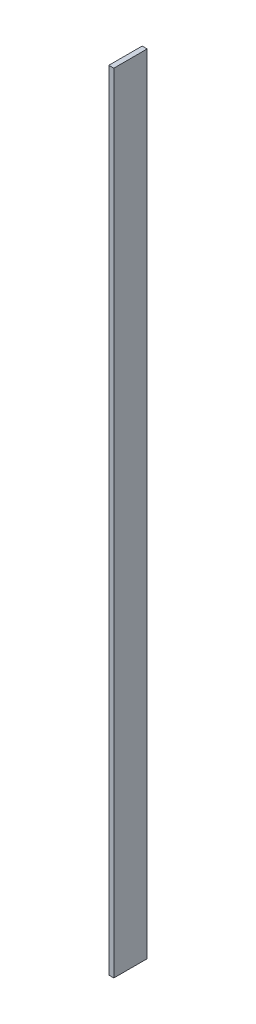
from build123d import *

# Parameters (mm, degrees)
SKETCH1_W           = 15.875
SKETCH1_H           = 374.65
BOSS_EXTRUDE1_DEPTH = 2.38125


with BuildPart() as part:
    # Sketch1 → Boss-Extrude1 (new body)
    with BuildSketch(Plane(origin=(0, 0, 0), x_dir=(0, 0, -1), z_dir=(1, 0, 0))):
        with Locations((7.9375, 187.325)):
            Rectangle(SKETCH1_W, SKETCH1_H)
    extrude(amount=BOSS_EXTRUDE1_DEPTH)


solid = part.part
